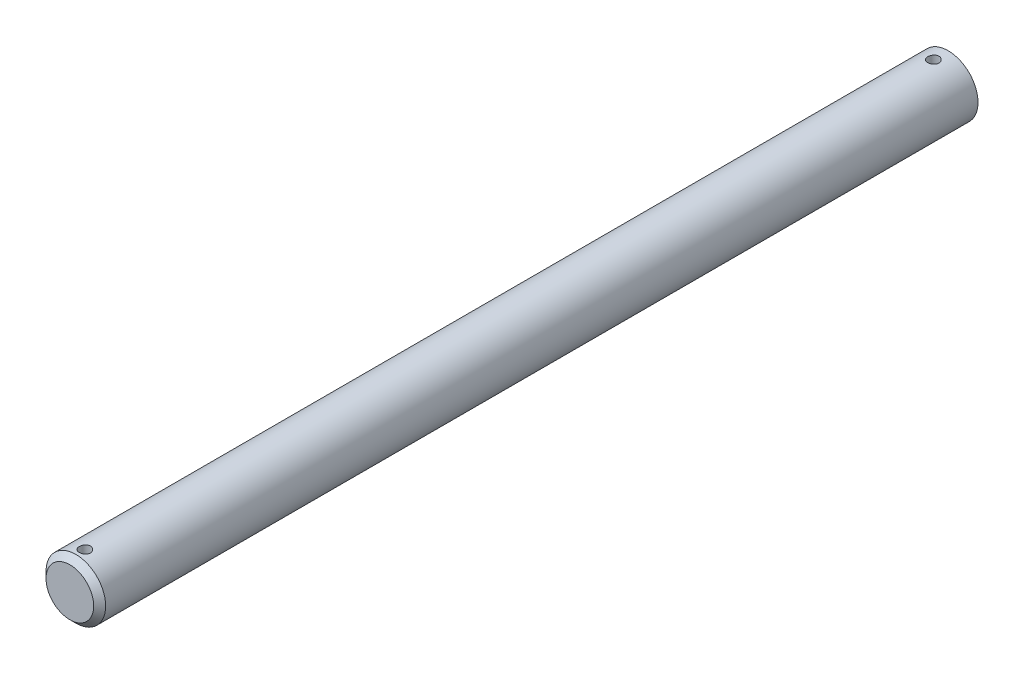
from build123d import *

# Parameters (mm, degrees)
SKETCH3_R               = 3.175
BOSS_EXTRUDE1_DEPTH     = 304.8
CHAMFER1_SIZE           = 0.635
CUT_EXTRUDE1_START      = -93.519625
SKETCH4_R               = 3.175
CUT_EXTRUDE1_DEPTH      = 517.080375
SKETCH5_R               = 0.5953125
CUT_EXTRUDE2_DEPTH      = 4.175
CUT_EXTRUDE2_DEPTH_BACK = 4.175


with BuildPart() as part:
    # Sketch3 → Boss-Extrude1 (new body, symmetric)
    with BuildSketch(Plane.XY):
        Circle(SKETCH3_R)
    extrude(amount=BOSS_EXTRUDE1_DEPTH, both=True)

    # Chamfer1
    chamfer1_edges = [part.edges().sort_by_distance(p)[0] for p in [
        (-3.175, 0, -304.8),
        (-3.175, 0, 304.8),
    ]]
    chamfer(chamfer1_edges, length=CHAMFER1_SIZE)

    # Sketch4 → Cut-Extrude1 (cut, through all)
    with BuildSketch(Plane.XY.offset(304.8).offset(CUT_EXTRUDE1_START)):
        Circle(SKETCH4_R)
    extrude(amount=-CUT_EXTRUDE1_DEPTH, mode=Mode.SUBTRACT)

    # Sketch5 → Cut-Extrude2 (cut, two sides)
    with BuildSketch(Plane(origin=(0, 0, 0), x_dir=(1, 0, 0), z_dir=(0, 1, 0))) as cut_extrude2_sk:
        with Locations((0, -212.867875)):
            Circle(SKETCH5_R)
        with Locations((0, -303.2125)):
            Circle(SKETCH5_R)
    extrude(amount=CUT_EXTRUDE2_DEPTH, mode=Mode.SUBTRACT)
    extrude(cut_extrude2_sk.sketch, amount=-CUT_EXTRUDE2_DEPTH_BACK, mode=Mode.SUBTRACT)


solid = part.part
